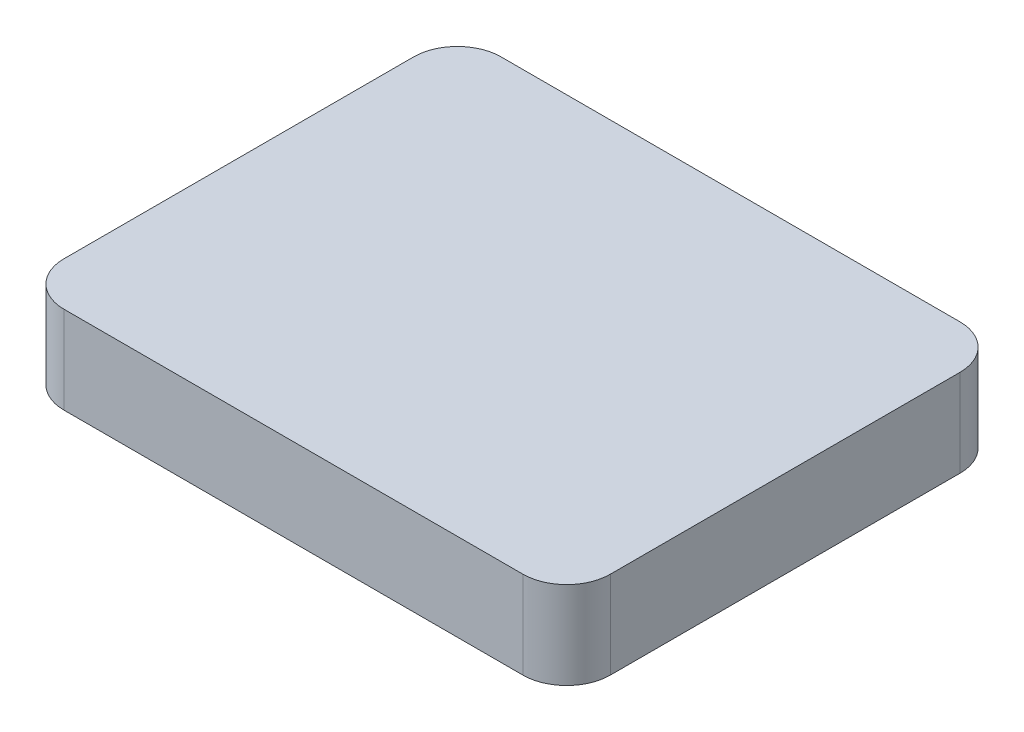
from build123d import *

# Parameters (mm, degrees)
BOSS_EXTRUDE2_DEPTH = 20


with BuildPart() as part:
    # Sketch2 → Boss-Extrude2 (new body, symmetric)
    with BuildSketch(Plane(origin=(0, 0, 0), x_dir=(1, 0, 0), z_dir=(0, 1, 0))):
        with BuildLine():
            Line((-105, 100), (105, 100))
            ThreePointArc((105, 100), (119.142135624, 94.142135624), (125, 80))
            Line((125, 80), (125, -80))
            ThreePointArc((125, -80), (119.142135624, -94.142135624), (105, -100))
            Line((105, -100), (-105, -100))
            ThreePointArc((-105, -100), (-119.142135624, -94.142135624), (-125, -80))
            Line((-125, -80), (-125, 80))
            ThreePointArc((-125, 80), (-119.142135624, 94.142135624), (-105, 100))
        make_face()
    extrude(amount=BOSS_EXTRUDE2_DEPTH, both=True)


solid = part.part
